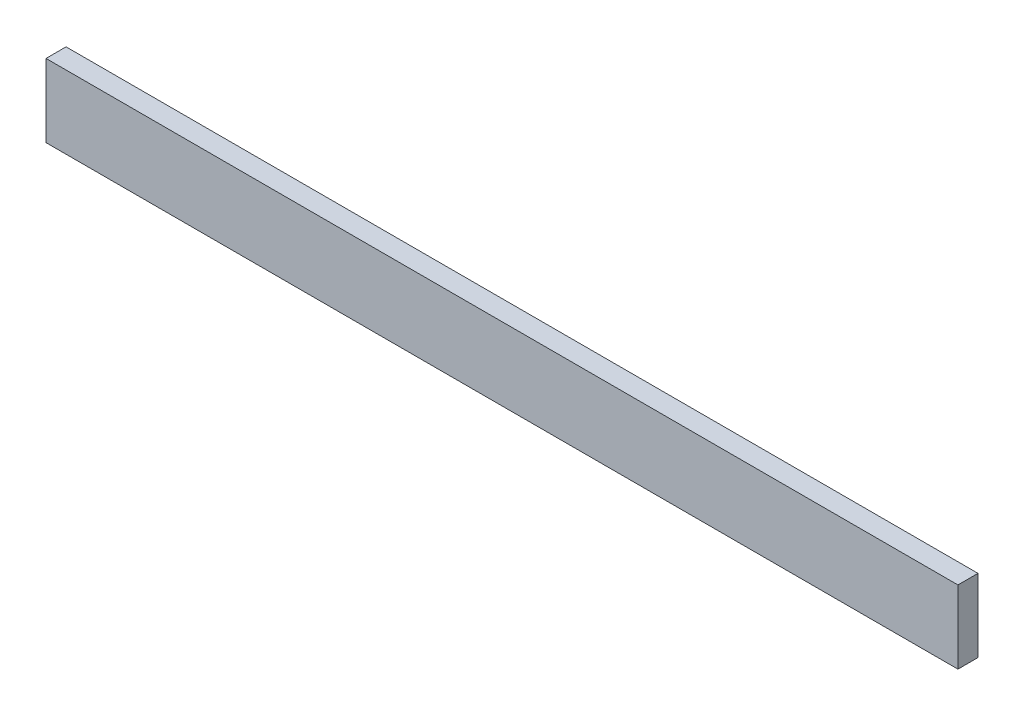
from build123d import *

# Parameters (mm, degrees)
ESQUISSE1_W      = 1000
ESQUISSE1_H      = 80
EXTRUSION1_DEPTH = 22


with BuildPart() as part:
    # Esquisse1 → Extrusion1 (new body)
    with BuildSketch(Plane.XY):
        with Locations((500, 40)):
            Rectangle(ESQUISSE1_W, ESQUISSE1_H)
    extrude(amount=EXTRUSION1_DEPTH)


solid = part.part
